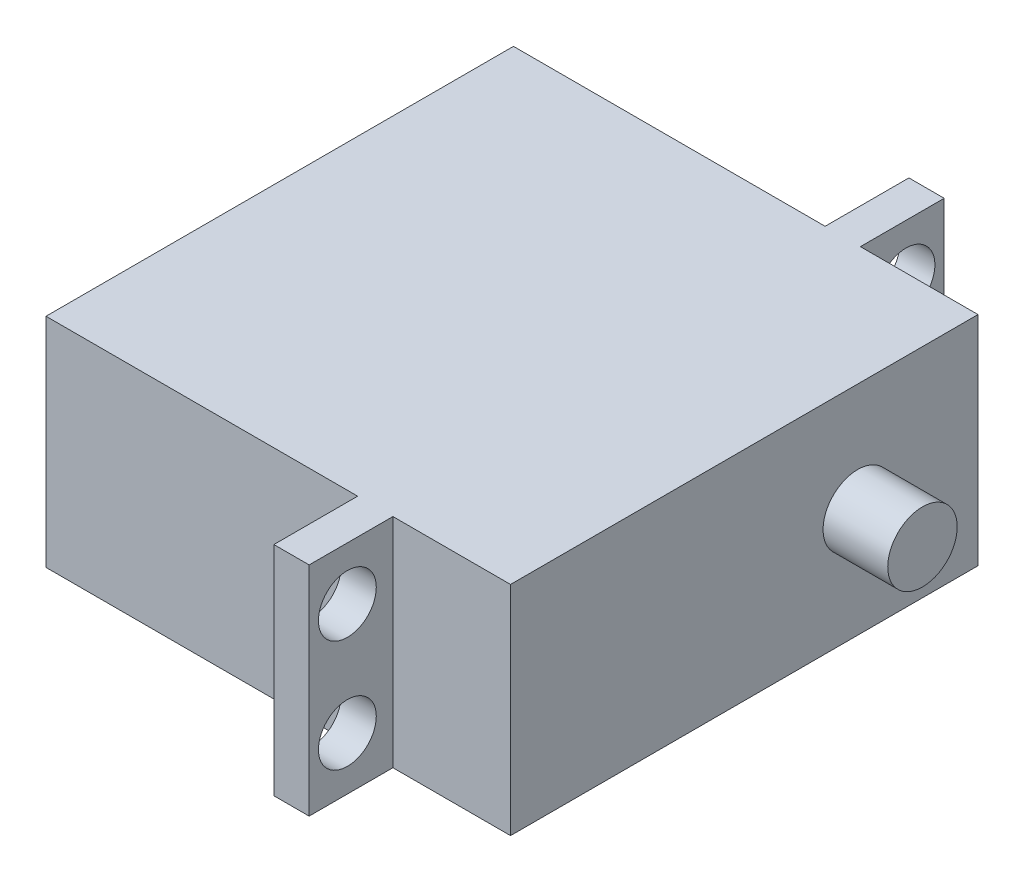
from build123d import *

# Parameters (mm, degrees)
SKETCH1_W           = 40.386
SKETCH1_H           = 18.796
BOSS_EXTRUDE1_DEPTH = 40.132
SKETCH2_W           = 7.239
SKETCH2_H           = 18.796
SKETCH2_R           = 2.5
BOSS_EXTRUDE2_DEPTH = 3.048
SKETCH3_R           = 3
BOSS_EXTRUDE3_DEPTH = 5.588


with BuildPart() as part:
    # Sketch1 → Boss-Extrude1 (new body)
    with BuildSketch(Plane(origin=(0, 0, 0), x_dir=(0, 0, -1), z_dir=(1, 0, 0))):
        with Locations((-20.193, -9.398)):
            Rectangle(SKETCH1_W, SKETCH1_H)
    extrude(amount=BOSS_EXTRUDE1_DEPTH)

    # Sketch2 → Boss-Extrude2 (add)
    with BuildSketch(Plane(origin=(26.924, 0, 0), x_dir=(0, 0, -1), z_dir=(1, 0, 0))):
        with Locations((-44.0055, -9.398)):
            Rectangle(SKETCH2_W, SKETCH2_H)
        with Locations((-44.323, -4.572)):
            Circle(SKETCH2_R, mode=Mode.SUBTRACT)
        with Locations((-44.323, -14.224)):
            Circle(SKETCH2_R, mode=Mode.SUBTRACT)
        with Locations((3.6195, -9.398)):
            Rectangle(SKETCH2_W, SKETCH2_H)
        with Locations((3.937, -4.572)):
            Circle(SKETCH2_R, mode=Mode.SUBTRACT)
        with Locations((3.937, -14.224)):
            Circle(SKETCH2_R, mode=Mode.SUBTRACT)
    extrude(amount=BOSS_EXTRUDE2_DEPTH)

    # Sketch3 → Boss-Extrude3 (add)
    with BuildSketch(Plane(origin=(40.132, 0, 0), x_dir=(0, 0, -1), z_dir=(1, 0, 0))):
        with Locations((-10.386, -9.398)):
            Circle(SKETCH3_R)
    extrude(amount=BOSS_EXTRUDE3_DEPTH)


solid = part.part
